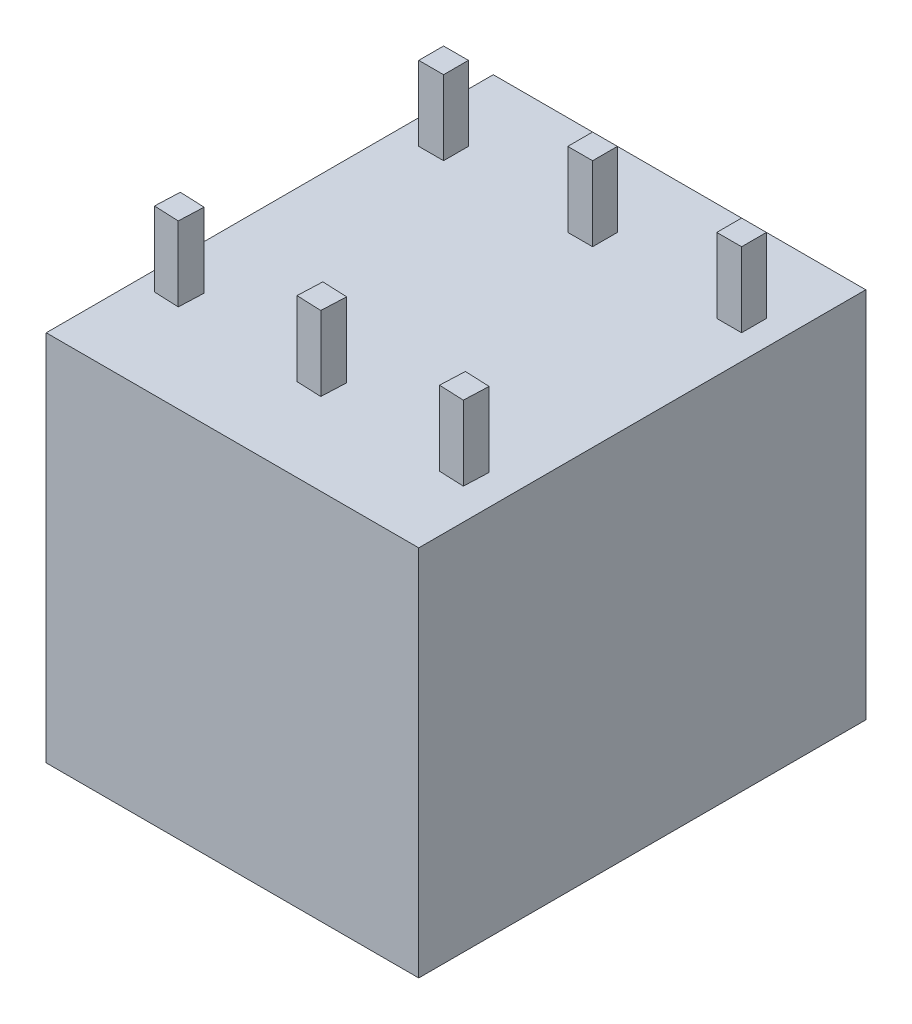
from build123d import *

# Parameters (mm, degrees)
ESQUISSE1_W        = 15
ESQUISSE1_H        = 18
BOSS_EXTRU_1_DEPTH = 15
ESQUISSE2_W        = 1
ESQUISSE2_H        = 1
BOSS_EXTRU_2_DEPTH = 3


with BuildPart() as part:
    # Esquisse1 → Boss.-Extru.1 (new body)
    with BuildSketch(Plane(origin=(0, 0, 0), x_dir=(1, 0, 0), z_dir=(0, 1, 0))):
        with Locations((7.5, 9)):
            Rectangle(ESQUISSE1_W, ESQUISSE1_H)
    extrude(amount=BOSS_EXTRU_1_DEPTH)

    # Esquisse2 → Boss.-Extru.2 (add)
    with BuildSketch(Plane(origin=(0, 15, 0), x_dir=(1, 0, 0), z_dir=(0, 1, 0))):
        with Locations((1.5, 14.5)):
            Rectangle(ESQUISSE2_W, ESQUISSE2_H)
        with Locations((7.5, 14.5)):
            Rectangle(ESQUISSE2_W, ESQUISSE2_H)
        with Locations((13.5, 14.5)):
            Rectangle(ESQUISSE2_W, ESQUISSE2_H)
        Polygon((12.746406665, 3.090573879), (12.788974359, 4.089667464), (13.788067944, 4.04709977), (13.745500249, 3.048006185), align=None)
        Polygon((7.75093874, 3.30341235), (7.793506434, 4.302505935), (6.794412849, 4.34507363), (6.751845155, 3.345980045), align=None)
        Polygon((1.756377231, 3.558818516), (1.798944925, 4.557912101), (0.79985134, 4.600479795), (0.757283646, 3.60138621), align=None)
    extrude(amount=BOSS_EXTRU_2_DEPTH)


solid = part.part
